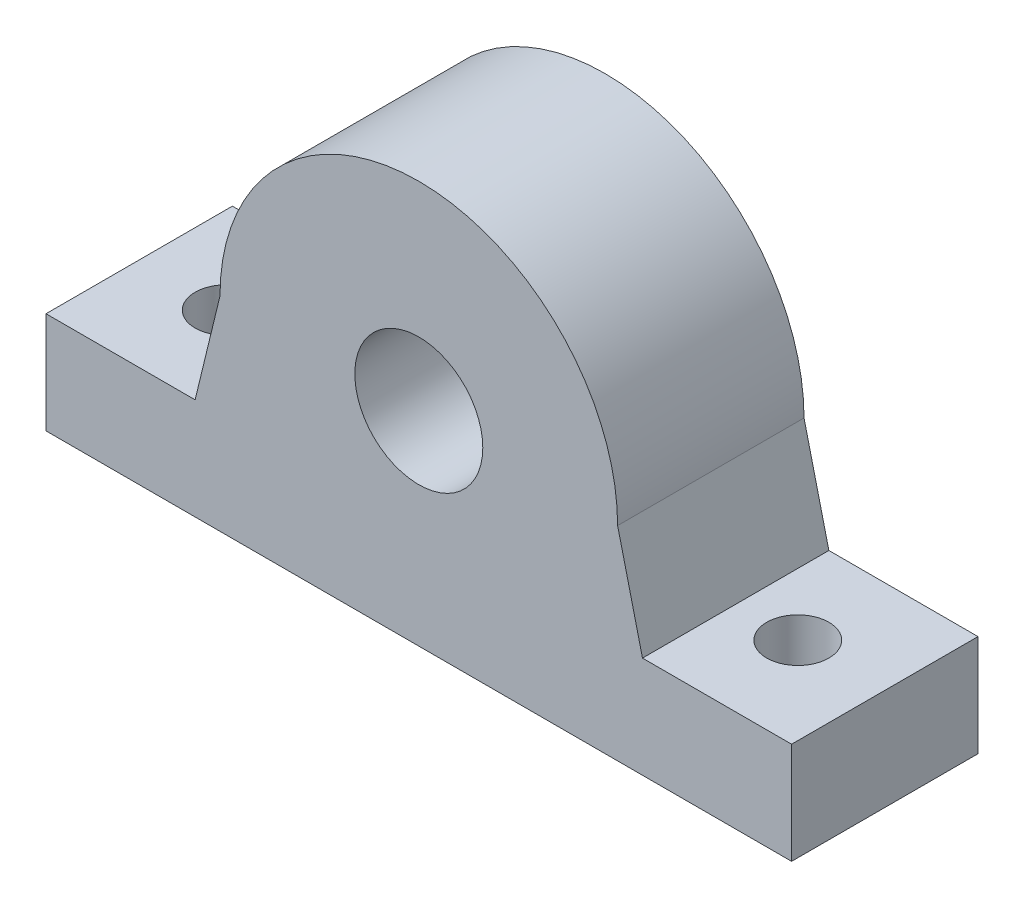
from build123d import *

# Parameters (mm, degrees)
SKETCH2_R           = 5.15
BOSS_EXTRUDE1_DEPTH = 15
SKETCH3_R           = 11
CUT_EXTRUDE1_DEPTH  = 4
SKETCH4_R           = 2.5
CUT_EXTRUDE2_DEPTH  = 9.165533085


with BuildPart() as part:
    # Sketch2 → Boss-Extrude1 (new body)
    with BuildSketch(Plane.XY):
        with BuildLine():
            Line((-16, 0), (-18, -8.234466915))
            Line((-18, -8.234466915), (-30, -8.234466915))
            Line((-30, -8.234466915), (-30, -16.4))
            Line((-30, -16.4), (30, -16.4))
            Line((30, -16.4), (30, -8.234466915))
            Line((30, -8.234466915), (18, -8.234466915))
            Line((18, -8.234466915), (16, 0))
            ThreePointArc((16, 0), (0, 16), (-16, 0))
        make_face()
        Circle(SKETCH2_R, mode=Mode.SUBTRACT)
    extrude(amount=BOSS_EXTRUDE1_DEPTH)

    # Sketch3 → Cut-Extrude1 (cut)
    with BuildSketch(Plane.XY):
        Circle(SKETCH3_R)
    extrude(amount=CUT_EXTRUDE1_DEPTH, mode=Mode.SUBTRACT)

    # Sketch4 → Cut-Extrude2 (cut, through all)
    with BuildSketch(Plane(origin=(0, -8.234466915, 0), x_dir=(1, 0, 0), z_dir=(0, 1, 0))):
        with Locations((-23, -7.5)):
            Circle(SKETCH4_R)
        with Locations((23, -7.5)):
            Circle(SKETCH4_R)
    extrude(amount=-CUT_EXTRUDE2_DEPTH, mode=Mode.SUBTRACT)


solid = part.part
